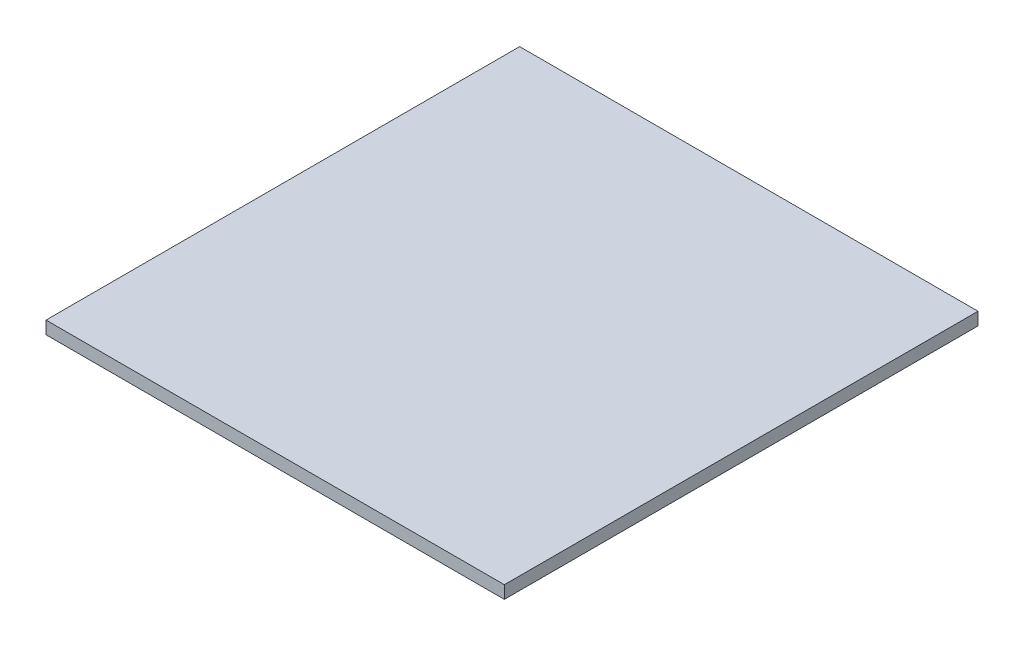
from build123d import *

# Parameters (mm, degrees)
SKETCH1_W           = 571.5
SKETCH1_H           = 590.55
BOSS_EXTRUDE1_DEPTH = 15.875


with BuildPart() as part:
    # Sketch1 → Boss-Extrude1 (new body)
    with BuildSketch(Plane(origin=(0, 0, 0), x_dir=(1, 0, 0), z_dir=(0, 1, 0))):
        with Locations((285.75, 295.275)):
            Rectangle(SKETCH1_W, SKETCH1_H)
    extrude(amount=BOSS_EXTRUDE1_DEPTH)


solid = part.part
